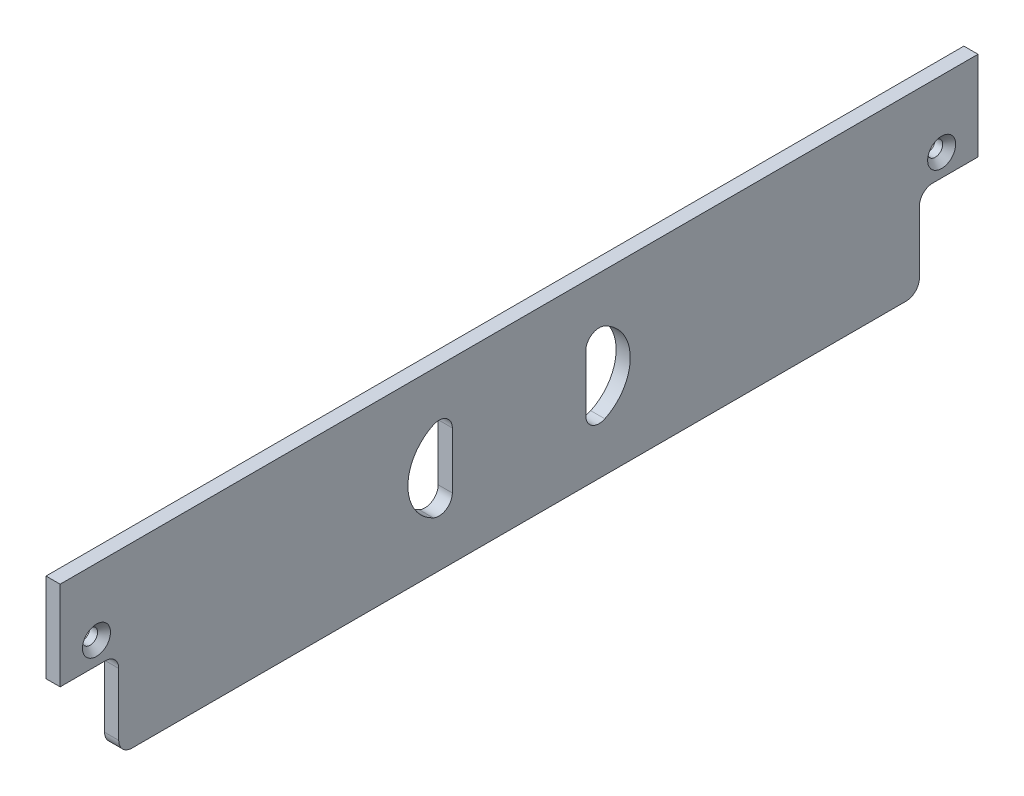
from build123d import *

# Parameters (mm, degrees)
BOSS_EXTRUDE1_DEPTH                             = 3.175
CSK_FOR_M3_FLAT_HEAD_MACHINE_SCREW1_D           = 3.4
CSK_FOR_M3_FLAT_HEAD_MACHINE_SCREW1_CSINK_D     = 6.3
CSK_FOR_M3_FLAT_HEAD_MACHINE_SCREW1_CSINK_ANGLE = 90
CUT_EXTRUDE1_DEPTH                              = 4.175
FILLET1_R                                       = 3
FILLET1_OF_MIRROR3_R                            = 3


with BuildPart() as part:
    # Sketch1 → Boss-Extrude1 (new body)
    with BuildSketch(Plane(origin=(0, 0, 0), x_dir=(0, 0, -1), z_dir=(1, 0, 0))):
        with BuildLine():
            Line((-103.175, 20), (-103.175, 40))
            Line((-103.175, 40), (103.175, 40))
            Line((103.175, 40), (103.175, 20))
            Line((103.175, 20), (93, 20))
            ThreePointArc((93, 20), (90.878679656, 19.121320344), (90, 17))
            Line((90, 17), (90, 3))
            ThreePointArc((90, 3), (89.121320344, 0.878679656), (87, 0))
            Line((87, 0), (-87, 0))
            ThreePointArc((-87, 0), (-89.121320344, 0.878679656), (-90, 3))
            Line((-90, 3), (-90, 17))
            ThreePointArc((-90, 17), (-90.878679656, 19.121320344), (-93, 20))
            Line((-93, 20), (-103.175, 20))
        make_face()
    extrude(amount=BOSS_EXTRUDE1_DEPTH)

    # CSK for M3 Flat Head Machine Screw1 (through all)
    with Locations(Plane(origin=(3.175, 0, 0), x_dir=(0, 0, -1), z_dir=(1, 0, 0))):
        with Locations((-95, 25)):
            csk_for_m3_flat_head_machine_screw1 = CounterSinkHole(CSK_FOR_M3_FLAT_HEAD_MACHINE_SCREW1_D / 2, CSK_FOR_M3_FLAT_HEAD_MACHINE_SCREW1_CSINK_D / 2, counter_sink_angle=CSK_FOR_M3_FLAT_HEAD_MACHINE_SCREW1_CSINK_ANGLE)

    # Mirror1: CSK for M3 Flat Head Machine Screw1 across plane
    add(csk_for_m3_flat_head_machine_screw1.mirror(Plane.XY), mode=Mode.SUBTRACT)

    # Sketch4 → Cut-Extrude1 (cut, through all)
    with BuildSketch(Plane(origin=(3.175, 0, 0), x_dir=(0, 0, -1), z_dir=(1, 0, 0))):
        with BuildLine():
            Line((-15, 30), (-15, 10))
            ThreePointArc((-15, 10), (-25, 20), (-15, 30))
        make_face()
    cut_extrude1 = extrude(amount=-CUT_EXTRUDE1_DEPTH, mode=Mode.SUBTRACT)

    # Fillet1
    fillet1_edges = [part.edges().sort_by_distance(p)[0] for p in [
        (1.5875, 10, 15),
        (1.5875, 30, 15),
    ]]
    fillet(fillet1_edges, radius=FILLET1_R)

    # Mirror3: Cut-Extrude1 across plane
    add(cut_extrude1.mirror(Plane.XY), mode=Mode.SUBTRACT)

    # Fillet1 of Mirror3
    fillet1_of_mirror3_edges = [part.edges().sort_by_distance(p)[0] for p in [
        (1.5875, 10, -15),
        (1.5875, 30, -15),
    ]]
    fillet(fillet1_of_mirror3_edges, radius=FILLET1_OF_MIRROR3_R)


solid = part.part
